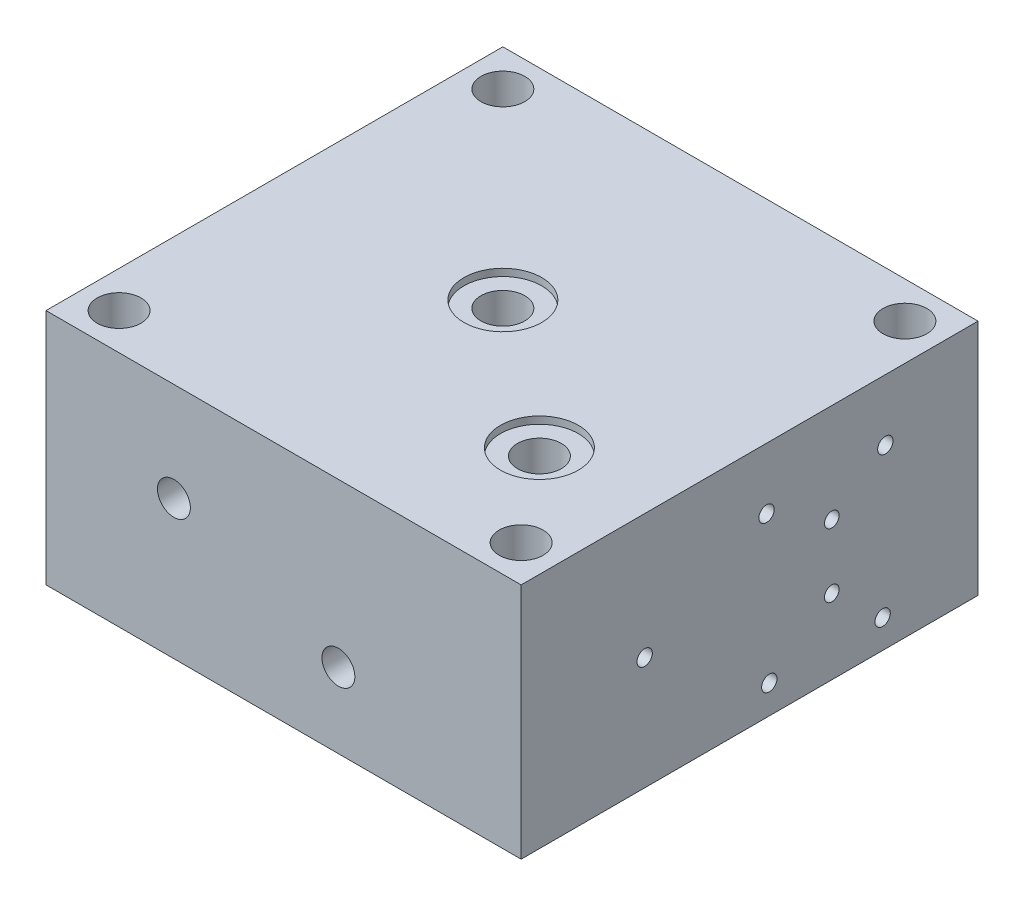
from build123d import *

# Parameters (mm, degrees)
SKETCH_2_W                 = 130
SKETCH_2_H                 = 125
SKETCH_2_R                 = 6
EXTRUDE_1_DEPTH            = 65
HOLE_WIZARD_M5_3_D         = 4.2
HOLE_WIZARD_M5_3_DEPTH     = 12
HOLE_WIZARD_M5_3_TIP       = 1.2618073
HOLE_WIZARD_4_0_4_9_D      = 4
HOLE_WIZARD_4_0_4_9_DEPTH  = 32.5
HOLE_WIZARD_4_0_4_9_TIP    = 1.201721238
HOLE_WIZARD_6_0_6_1_D      = 6
HOLE_WIZARD_6_0_6_1_DEPTH  = 42
HOLE_WIZARD_6_0_6_1_TIP    = 1.802581857
HOLE_WIZARD_4_0_4_11_D     = 4
HOLE_WIZARD_4_0_4_11_DEPTH = 85
HOLE_WIZARD_4_0_4_11_TIP   = 1.201721238
M10X1_0_1_D                = 9
M10X1_0_1_DEPTH            = 13
M10X1_0_1_TIP              = 2.703872786
HOLE_WIZARD_M5_5_D         = 4.2
HOLE_WIZARD_M5_5_DEPTH     = 10
HOLE_WIZARD_M5_5_TIP       = 1.2618073
HOLE_WIZARD_6_0_6_2_D      = 6
HOLE_WIZARD_6_0_6_2_DEPTH  = 60
HOLE_WIZARD_6_0_6_2_TIP    = 1.802581857
HOLE_WIZARD_6_0_6_3_D      = 6
HOLE_WIZARD_6_0_6_3_DEPTH  = 90
HOLE_WIZARD_6_0_6_3_TIP    = 1.802581857
HOLE_WIZARD_M5_8_D         = 4.2
HOLE_WIZARD_M5_8_DEPTH     = 41.31
HOLE_WIZARD_M5_8_TIP       = 1.2618073
HOLE_WIZARD_6_0_6_4_D      = 6
M10X1_0_2_D                = 9
M10X1_0_2_DEPTH            = 13
M10X1_0_2_TIP              = 2.703872786
SKETCH_73_R                = 10.65
CUT_EXTRUDE_1_DEPTH        = 1.97
SKETCH_74_R                = 6
CUT_EXTRUDE_2_DEPTH        = 64.03
SKETCH_75_R                = 10.65
CUT_EXTRUDE_3_DEPTH        = 1.97
SKETCH_76_R                = 6
CUT_EXTRUDE_4_DEPTH        = 64.03
SKETCH_82_R                = 2
CUT_EXTRUDE_6_DEPTH        = 97
SKETCH_83_R                = 6
CUT_EXTRUDE_7_DEPTH        = 13


with BuildPart() as part:
    # 草图2 → 凸台-拉伸1 (new body)
    with BuildSketch(Plane(origin=(0, 0, 0), x_dir=(1, 0, 0), z_dir=(0, 1, 0))):
        Rectangle(SKETCH_2_W, SKETCH_2_H)
        with Locations((-55, 52.5)):
            Circle(SKETCH_2_R, mode=Mode.SUBTRACT)
        with Locations((55, 52.5)):
            Circle(SKETCH_2_R, mode=Mode.SUBTRACT)
        with Locations((55, -52.5)):
            Circle(SKETCH_2_R, mode=Mode.SUBTRACT)
        with Locations((-55, -52.5)):
            Circle(SKETCH_2_R, mode=Mode.SUBTRACT)
    extrude(amount=EXTRUDE_1_DEPTH)

    # M5 螺纹孔3
    with Locations(Plane(origin=(65, 48.3, -4.65), x_dir=(0, 0, 1), z_dir=(1, 0, 0))):
        with Locations((0, 0), (-32.5, 0), (-31.75, 40.5), (-0.75, 40.5)):
            Hole(HOLE_WIZARD_M5_3_D / 2, depth=HOLE_WIZARD_M5_3_DEPTH)
            with Locations((0, 0, -(HOLE_WIZARD_M5_3_DEPTH + HOLE_WIZARD_M5_3_TIP / 2))):  # 118° drill point
                Cone(0, HOLE_WIZARD_M5_3_D / 2, HOLE_WIZARD_M5_3_TIP, mode=Mode.SUBTRACT)

    # Ø4.0 (4) 直径孔9
    with Locations(Plane(origin=(65, 20.5, -22.49541266), x_dir=(0, 0, 1), z_dir=(1, 0, 0))):
        with Locations((0, 0)):
            Hole(HOLE_WIZARD_4_0_4_9_D / 2, depth=HOLE_WIZARD_4_0_4_9_DEPTH)
            with Locations((0, 0, -(HOLE_WIZARD_4_0_4_9_DEPTH + HOLE_WIZARD_4_0_4_9_TIP / 2))):  # 118° drill point
                Cone(0, HOLE_WIZARD_4_0_4_9_D / 2, HOLE_WIZARD_4_0_4_9_TIP, mode=Mode.SUBTRACT)

    # Ø6.0 (6) 直径孔1
    with Locations(Plane(origin=(32.5, 20.5, -62.5), x_dir=(-1, 0, 0), z_dir=(0, 0, -1))):
        with Locations((0, 0)):
            Hole(HOLE_WIZARD_6_0_6_1_D / 2, depth=HOLE_WIZARD_6_0_6_1_DEPTH)
            with Locations((0, 0, -(HOLE_WIZARD_6_0_6_1_DEPTH + HOLE_WIZARD_6_0_6_1_TIP / 2))):  # 118° drill point
                Cone(0, HOLE_WIZARD_6_0_6_1_D / 2, HOLE_WIZARD_6_0_6_1_TIP, mode=Mode.SUBTRACT)

    # Ø4.0 (4) 直径孔11
    with Locations(Plane(origin=(-30, 38, 62.5), x_dir=(1, 0, 0), z_dir=(0, 0, 1))):
        with Locations((0, 0)):
            Hole(HOLE_WIZARD_4_0_4_11_D / 2, depth=HOLE_WIZARD_4_0_4_11_DEPTH)
            with Locations((0, 0, -(HOLE_WIZARD_4_0_4_11_DEPTH + HOLE_WIZARD_4_0_4_11_TIP / 2))):  # 118° drill point
                Cone(0, HOLE_WIZARD_4_0_4_11_D / 2, HOLE_WIZARD_4_0_4_11_TIP, mode=Mode.SUBTRACT)

    # M10x1.0 螺纹孔1
    with Locations(Plane(origin=(-30, 38, 62.5), x_dir=(1, 0, 0), z_dir=(0, 0, 1))):
        with Locations((0, 0)):
            Hole(M10X1_0_1_D / 2, depth=M10X1_0_1_DEPTH)
            with Locations((0, 0, -(M10X1_0_1_DEPTH + M10X1_0_1_TIP / 2))):  # 118° drill point
                Cone(0, M10X1_0_1_D / 2, M10X1_0_1_TIP, mode=Mode.SUBTRACT)

    # M5 螺纹孔5
    with Locations(Plane(origin=(4.7, 36, -62.5), x_dir=(-1, 0, 0), z_dir=(0, 0, -1))):
        with Locations((0, 0), (-40.5, 0), (-40.5, -31), (0, -31)):
            Hole(HOLE_WIZARD_M5_5_D / 2, depth=HOLE_WIZARD_M5_5_DEPTH)
            with Locations((0, 0, -(HOLE_WIZARD_M5_5_DEPTH + HOLE_WIZARD_M5_5_TIP / 2))):  # 118° drill point
                Cone(0, HOLE_WIZARD_M5_5_D / 2, HOLE_WIZARD_M5_5_TIP, mode=Mode.SUBTRACT)

    # Ø6.0 (6) 直径孔2
    with Locations(Plane(origin=(23.7, 10.1, -62.5), x_dir=(-1, 0, 0), z_dir=(0, 0, -1))):
        with Locations((0, 0)):
            Hole(HOLE_WIZARD_6_0_6_2_D / 2, depth=HOLE_WIZARD_6_0_6_2_DEPTH)
            with Locations((0, 0, -(HOLE_WIZARD_6_0_6_2_DEPTH + HOLE_WIZARD_6_0_6_2_TIP / 2))):  # 118° drill point
                Cone(0, HOLE_WIZARD_6_0_6_2_D / 2, HOLE_WIZARD_6_0_6_2_TIP, mode=Mode.SUBTRACT)

    # Ø6.0 (6) 直径孔3
    with Locations(Plane(origin=(23.7, 30.9, -62.5), x_dir=(-1, 0, 0), z_dir=(0, 0, -1))):
        with Locations((0, 0)):
            Hole(HOLE_WIZARD_6_0_6_3_D / 2, depth=HOLE_WIZARD_6_0_6_3_DEPTH)
            with Locations((0, 0, -(HOLE_WIZARD_6_0_6_3_DEPTH + HOLE_WIZARD_6_0_6_3_TIP / 2))):  # 118° drill point
                Cone(0, HOLE_WIZARD_6_0_6_3_D / 2, HOLE_WIZARD_6_0_6_3_TIP, mode=Mode.SUBTRACT)

    # M5 螺纹孔8
    with Locations(Plane(origin=(65, 30.9, 28.70458734), x_dir=(0, 0, 1), z_dir=(1, 0, 0))):
        with Locations((0, 0)):
            Hole(HOLE_WIZARD_M5_8_D / 2, depth=HOLE_WIZARD_M5_8_DEPTH)
            with Locations((0, 0, -(HOLE_WIZARD_M5_8_DEPTH + HOLE_WIZARD_M5_8_TIP / 2))):  # 118° drill point
                Cone(0, HOLE_WIZARD_M5_8_D / 2, HOLE_WIZARD_M5_8_TIP, mode=Mode.SUBTRACT)

    # Ø6.0 (6) 直径孔4 (through all)
    with Locations(Plane(origin=(15, 20.5, -62.5), x_dir=(-1, 0, 0), z_dir=(0, 0, -1))):
        with Locations((0, 0)):
            Hole(HOLE_WIZARD_6_0_6_4_D / 2)

    # M10x1.0 螺纹孔2
    with Locations(Plane(origin=(15, 20.5, 62.5), x_dir=(1, 0, 0), z_dir=(0, 0, 1))):
        with Locations((0, 0)):
            Hole(M10X1_0_2_D / 2, depth=M10X1_0_2_DEPTH)
            with Locations((0, 0, -(M10X1_0_2_DEPTH + M10X1_0_2_TIP / 2))):  # 118° drill point
                Cone(0, M10X1_0_2_D / 2, M10X1_0_2_TIP, mode=Mode.SUBTRACT)

    # 草图73 → 切除-拉伸1 (cut)
    with BuildSketch(Plane(origin=(0, 65, 0), x_dir=(1, 0, 0), z_dir=(0, 1, 0))):
        with Locations((-5, 2.5)):
            Circle(SKETCH_73_R)
    extrude(amount=-CUT_EXTRUDE_1_DEPTH, mode=Mode.SUBTRACT)

    # 草图74 → 切除-拉伸2 (cut, through all)
    with BuildSketch(Plane(origin=(0, 63.03, 0), x_dir=(1, 0, 0), z_dir=(0, 1, 0))):
        with Locations((-5, 2.5)):
            Circle(SKETCH_74_R)
    extrude(amount=-CUT_EXTRUDE_2_DEPTH, mode=Mode.SUBTRACT)

    # 草图75 → 切除-拉伸3 (cut)
    with BuildSketch(Plane(origin=(0, 65, 0), x_dir=(1, 0, 0), z_dir=(0, 1, 0))):
        with Locations((35, -27.5)):
            Circle(SKETCH_75_R)
    extrude(amount=-CUT_EXTRUDE_3_DEPTH, mode=Mode.SUBTRACT)

    # 草图76 → 切除-拉伸4 (cut, through all)
    with BuildSketch(Plane(origin=(0, 63.03, 0), x_dir=(1, 0, 0), z_dir=(0, 1, 0))):
        with Locations((35, -27.5)):
            Circle(SKETCH_76_R)
    extrude(amount=-CUT_EXTRUDE_4_DEPTH, mode=Mode.SUBTRACT)

    # 草图82 → 切除-拉伸6 (cut)
    with BuildSketch(Plane(origin=(65, 0, 0), x_dir=(0, 0, -1), z_dir=(1, 0, 0))):
        with Locations((22.5, 38)):
            Circle(SKETCH_82_R)
    extrude(amount=-CUT_EXTRUDE_6_DEPTH, mode=Mode.SUBTRACT)

    # 草图83 → 切除-拉伸7 (cut)
    with BuildSketch(Plane(origin=(0, 0, 0), x_dir=(-1, 0, 0), z_dir=(0, -1, 0))):
        with Locations((-23, 3.7)):
            Circle(SKETCH_83_R)
    extrude(amount=-CUT_EXTRUDE_7_DEPTH, mode=Mode.SUBTRACT)


solid = part.part
